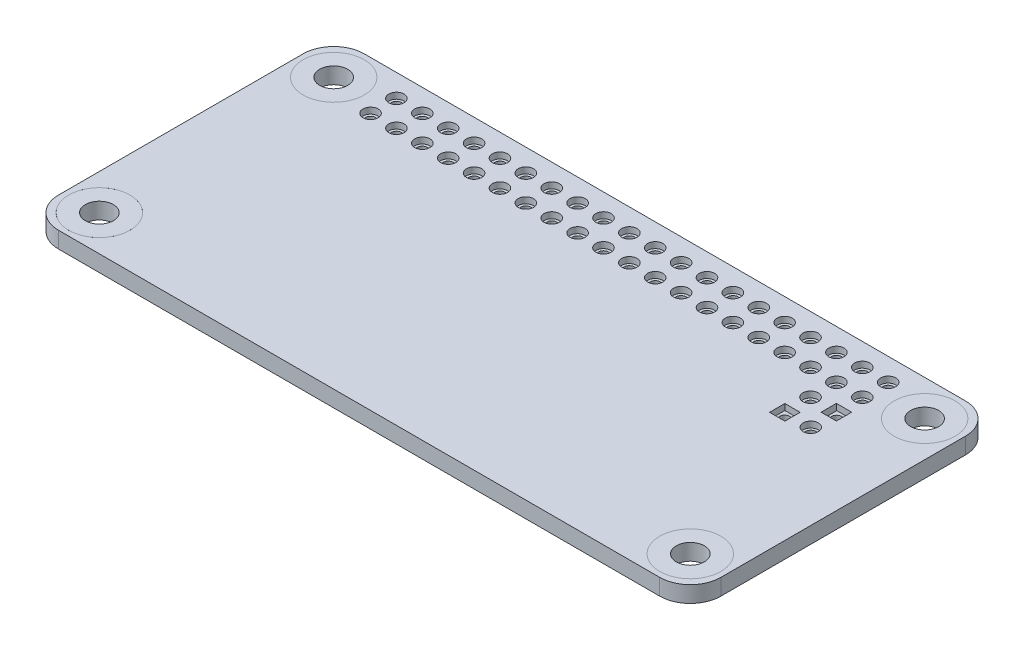
from build123d import *

# Parameters (mm, degrees)
SKETCH1_R             = 3
SKETCH1_R_2           = 0.75
SKETCH1_W             = 1.5
SKETCH1_H             = 1.5
BOSS_EXTRUDE1_DEPTH   = 1.6
SKETCH2_R             = 0.75
SKETCH2_R_2           = 0.5
BOSS_EXTRUDE2_DEPTH   = 1
LPATTERN2_COUNT       = 20
LPATTERN2_PITCH       = 2.54
LPATTERN2_2_COUNT     = 2
LPATTERN2_2_PITCH     = 2.54
SKETCH3_R             = 0.75
SKETCH3_R_2           = 0.5
BOSS_EXTRUDE3_DEPTH   = 1
BOSS_EXTRUDE3_2_DEPTH = 1
SKETCH3_W             = 1.541222488
SKETCH3_H             = 1.5
BOSS_EXTRUDE3_3_DEPTH = 1
SKETCH3_W_2           = 1.458777511
BOSS_EXTRUDE3_4_DEPTH = 1
SKETCH4_R             = 3
SKETCH4_R_2           = 1.375
BOSS_EXTRUDE4_DEPTH   = 1.6
CUT_EXTRUDE1_DEPTH    = 1


with BuildPart() as part:
    # Sketch1 → Boss-Extrude1 (new body)
    with BuildSketch(Plane(origin=(0, 0, 0), x_dir=(1, 0, 0), z_dir=(0, 1, 0))):
        with BuildLine():
            Line((-29.5, -15), (29.5, -15))
            ThreePointArc((29.5, -15), (31.621320344, -14.121320344), (32.5, -12))
            Line((32.5, -12), (32.5, 12))
            ThreePointArc((32.5, 12), (31.621320344, 14.121320344), (29.5, 15))
            Line((29.5, 15), (-29.5, 15))
            ThreePointArc((-29.5, 15), (-31.621320344, 14.121320344), (-32.5, 12))
            Line((-32.5, 12), (-32.5, -12))
            ThreePointArc((-32.5, -12), (-31.621320344, -14.121320344), (-29.5, -15))
        make_face()
        with Locations((-29, 11.5)):
            Circle(SKETCH1_R, mode=Mode.SUBTRACT)
        with Locations((-29, -11.5)):
            Circle(SKETCH1_R, mode=Mode.SUBTRACT)
        with Locations((29, -11.5)):
            Circle(SKETCH1_R, mode=Mode.SUBTRACT)
        with Locations((-24.13, 12.787653136)):
            Circle(SKETCH1_R_2, mode=Mode.SUBTRACT)
        with Locations((-21.59, 12.787653136)):
            Circle(SKETCH1_R_2, mode=Mode.SUBTRACT)
        with Locations((-19.05, 12.787653136)):
            Circle(SKETCH1_R_2, mode=Mode.SUBTRACT)
        with Locations((-16.51, 12.787653136)):
            Circle(SKETCH1_R_2, mode=Mode.SUBTRACT)
        with Locations((-13.97, 12.787653136)):
            Circle(SKETCH1_R_2, mode=Mode.SUBTRACT)
        with Locations((-11.43, 12.787653136)):
            Circle(SKETCH1_R_2, mode=Mode.SUBTRACT)
        with Locations((-8.89, 12.787653136)):
            Circle(SKETCH1_R_2, mode=Mode.SUBTRACT)
        with Locations((-6.35, 12.787653136)):
            Circle(SKETCH1_R_2, mode=Mode.SUBTRACT)
        with Locations((-3.81, 12.787653136)):
            Circle(SKETCH1_R_2, mode=Mode.SUBTRACT)
        with Locations((-1.27, 12.787653136)):
            Circle(SKETCH1_R_2, mode=Mode.SUBTRACT)
        with Locations((1.27, 12.787653136)):
            Circle(SKETCH1_R_2, mode=Mode.SUBTRACT)
        with Locations((3.81, 12.787653136)):
            Circle(SKETCH1_R_2, mode=Mode.SUBTRACT)
        with Locations((6.35, 12.787653136)):
            Circle(SKETCH1_R_2, mode=Mode.SUBTRACT)
        with Locations((8.89, 12.787653136)):
            Circle(SKETCH1_R_2, mode=Mode.SUBTRACT)
        with Locations((11.43, 12.787653136)):
            Circle(SKETCH1_R_2, mode=Mode.SUBTRACT)
        with Locations((13.97, 12.787653136)):
            Circle(SKETCH1_R_2, mode=Mode.SUBTRACT)
        with Locations((16.51, 12.787653136)):
            Circle(SKETCH1_R_2, mode=Mode.SUBTRACT)
        with Locations((19.05, 12.787653136)):
            Circle(SKETCH1_R_2, mode=Mode.SUBTRACT)
        with Locations((21.59, 12.787653136)):
            Circle(SKETCH1_R_2, mode=Mode.SUBTRACT)
        with Locations((24.13, 12.787653136)):
            Circle(SKETCH1_R_2, mode=Mode.SUBTRACT)
        with Locations((-21.59, 10.247653136)):
            Circle(SKETCH1_R_2, mode=Mode.SUBTRACT)
        with Locations((-19.05, 10.247653136)):
            Circle(SKETCH1_R_2, mode=Mode.SUBTRACT)
        with Locations((-16.51, 10.247653136)):
            Circle(SKETCH1_R_2, mode=Mode.SUBTRACT)
        with Locations((-13.97, 10.247653136)):
            Circle(SKETCH1_R_2, mode=Mode.SUBTRACT)
        with Locations((-11.43, 10.247653136)):
            Circle(SKETCH1_R_2, mode=Mode.SUBTRACT)
        with Locations((-8.89, 10.247653136)):
            Circle(SKETCH1_R_2, mode=Mode.SUBTRACT)
        with Locations((-6.35, 10.247653136)):
            Circle(SKETCH1_R_2, mode=Mode.SUBTRACT)
        with Locations((-3.81, 10.247653136)):
            Circle(SKETCH1_R_2, mode=Mode.SUBTRACT)
        with Locations((-1.27, 10.247653136)):
            Circle(SKETCH1_R_2, mode=Mode.SUBTRACT)
        with Locations((1.27, 10.247653136)):
            Circle(SKETCH1_R_2, mode=Mode.SUBTRACT)
        with Locations((3.81, 10.247653136)):
            Circle(SKETCH1_R_2, mode=Mode.SUBTRACT)
        with Locations((6.35, 10.247653136)):
            Circle(SKETCH1_R_2, mode=Mode.SUBTRACT)
        with Locations((8.89, 10.247653136)):
            Circle(SKETCH1_R_2, mode=Mode.SUBTRACT)
        with Locations((11.43, 10.247653136)):
            Circle(SKETCH1_R_2, mode=Mode.SUBTRACT)
        with Locations((13.97, 10.247653136)):
            Circle(SKETCH1_R_2, mode=Mode.SUBTRACT)
        with Locations((16.51, 10.247653136)):
            Circle(SKETCH1_R_2, mode=Mode.SUBTRACT)
        with Locations((19.05, 10.247653136)):
            Circle(SKETCH1_R_2, mode=Mode.SUBTRACT)
        with Locations((21.59, 10.247653136)):
            Circle(SKETCH1_R_2, mode=Mode.SUBTRACT)
        with Locations((24.13, 10.247653136)):
            Circle(SKETCH1_R_2, mode=Mode.SUBTRACT)
        with Locations((-24.13, 10.247653136)):
            Circle(SKETCH1_R_2, mode=Mode.SUBTRACT)
        with Locations((21.59002512, 7.707653136)):
            Circle(SKETCH1_R_2, mode=Mode.SUBTRACT)
        with Locations((24.150636364, 5.167736764)):
            Circle(SKETCH1_R_2, mode=Mode.SUBTRACT)
        with Locations((29, 11.5)):
            Circle(SKETCH1_R, mode=Mode.SUBTRACT)
        with Locations((24.13002512, 7.707653136)):
            Rectangle(SKETCH1_W, SKETCH1_H, mode=Mode.SUBTRACT)
        with Locations((21.610636364, 5.167736764)):
            Rectangle(SKETCH1_W, SKETCH1_H, mode=Mode.SUBTRACT)
    extrude(amount=BOSS_EXTRUDE1_DEPTH)

    # Sketch5 → Cut-Extrude1 (cut)
    with BuildSketch(Plane.XZ):
        with BuildLine():
            Line((-26.078842351, 13.039495396), (-26.078842351, 13.539495396))
            ThreePointArc((-26.078842351, 13.539495396), (-25.578842351, 14.039495396), (-25.078842351, 13.539495396))
            Line((-25.078842351, 13.539495396), (-25.078842351, 13.039495396))
            ThreePointArc((-25.078842351, 13.039495396), (-25.578842351, 12.539495396), (-26.078842351, 13.039495396))
        make_face()
        with BuildLine():
            Line((-15.178842351, 13.039495396), (-15.178842351, 13.539495396))
            ThreePointArc((-15.178842351, 13.539495396), (-14.678842351, 14.039495396), (-14.178842351, 13.539495396))
            Line((-14.178842351, 13.539495396), (-14.178842351, 13.039495396))
            ThreePointArc((-14.178842351, 13.039495396), (-14.678842351, 12.539495396), (-15.178842351, 13.039495396))
        make_face()
        with BuildLine():
            Line((-15.178842351, 8.539495396), (-15.178842351, 9.039495396))
            ThreePointArc((-15.178842351, 9.039495396), (-14.678842351, 9.539495396), (-14.178842351, 9.039495396))
            Line((-14.178842351, 9.039495396), (-14.178842351, 8.539495396))
            ThreePointArc((-14.178842351, 8.539495396), (-14.678842351, 8.039495396), (-15.178842351, 8.539495396))
        make_face()
        with BuildLine():
            Line((-26.078842351, 8.539495396), (-26.078842351, 9.039495396))
            ThreePointArc((-26.078842351, 9.039495396), (-25.578842351, 9.539495396), (-25.078842351, 9.039495396))
            Line((-25.078842351, 9.039495396), (-25.078842351, 8.539495396))
            ThreePointArc((-25.078842351, 8.539495396), (-25.578842351, 8.039495396), (-26.078842351, 8.539495396))
        make_face()
    extrude(amount=-CUT_EXTRUDE1_DEPTH, mode=Mode.SUBTRACT)


with BuildPart() as body_2:
    # Sketch2 → Boss-Extrude2 (new body)
    with BuildSketch(Plane(origin=(0, 0, 0), x_dir=(1, 0, 0), z_dir=(0, 1, 0))):
        with Locations((-24.13, 12.787653136)):
            Circle(SKETCH2_R)
        with Locations((-24.13, 12.787653136)):
            Circle(SKETCH2_R_2, mode=Mode.SUBTRACT)
    extrude(amount=BOSS_EXTRUDE2_DEPTH)


with BuildPart() as lpattern2_1:
    # LPattern2: pattern copy
    add(body_2.part.moved(Location(Vector(1, 0, 0) * (1 * LPATTERN2_PITCH))))


with BuildPart() as lpattern2_2:
    # LPattern2: pattern copy
    add(body_2.part.moved(Location(Vector(1, 0, 0) * (2 * LPATTERN2_PITCH))))


with BuildPart() as lpattern2_3:
    # LPattern2: pattern copy
    add(body_2.part.moved(Location(Vector(1, 0, 0) * (3 * LPATTERN2_PITCH))))


with BuildPart() as lpattern2_4:
    # LPattern2: pattern copy
    add(body_2.part.moved(Location(Vector(1, 0, 0) * (4 * LPATTERN2_PITCH))))


with BuildPart() as lpattern2_5:
    # LPattern2: pattern copy
    add(body_2.part.moved(Location(Vector(1, 0, 0) * (5 * LPATTERN2_PITCH))))


with BuildPart() as lpattern2_6:
    # LPattern2: pattern copy
    add(body_2.part.moved(Location(Vector(1, 0, 0) * (6 * LPATTERN2_PITCH))))


with BuildPart() as lpattern2_7:
    # LPattern2: pattern copy
    add(body_2.part.moved(Location(Vector(1, 0, 0) * (7 * LPATTERN2_PITCH))))


with BuildPart() as lpattern2_8:
    # LPattern2: pattern copy
    add(body_2.part.moved(Location(Vector(1, 0, 0) * (8 * LPATTERN2_PITCH))))


with BuildPart() as lpattern2_9:
    # LPattern2: pattern copy
    add(body_2.part.moved(Location(Vector(1, 0, 0) * (9 * LPATTERN2_PITCH))))


with BuildPart() as lpattern2_10:
    # LPattern2: pattern copy
    add(body_2.part.moved(Location(Vector(1, 0, 0) * (10 * LPATTERN2_PITCH))))


with BuildPart() as lpattern2_11:
    # LPattern2: pattern copy
    add(body_2.part.moved(Location(Vector(1, 0, 0) * (11 * LPATTERN2_PITCH))))


with BuildPart() as lpattern2_12:
    # LPattern2: pattern copy
    add(body_2.part.moved(Location(Vector(1, 0, 0) * (12 * LPATTERN2_PITCH))))


with BuildPart() as lpattern2_13:
    # LPattern2: pattern copy
    add(body_2.part.moved(Location(Vector(1, 0, 0) * (13 * LPATTERN2_PITCH))))


with BuildPart() as lpattern2_14:
    # LPattern2: pattern copy
    add(body_2.part.moved(Location(Vector(1, 0, 0) * (14 * LPATTERN2_PITCH))))


with BuildPart() as lpattern2_15:
    # LPattern2: pattern copy
    add(body_2.part.moved(Location(Vector(1, 0, 0) * (15 * LPATTERN2_PITCH))))


with BuildPart() as lpattern2_16:
    # LPattern2: pattern copy
    add(body_2.part.moved(Location(Vector(1, 0, 0) * (16 * LPATTERN2_PITCH))))


with BuildPart() as lpattern2_17:
    # LPattern2: pattern copy
    add(body_2.part.moved(Location(Vector(1, 0, 0) * (17 * LPATTERN2_PITCH))))


with BuildPart() as lpattern2_18:
    # LPattern2: pattern copy
    add(body_2.part.moved(Location(Vector(1, 0, 0) * (18 * LPATTERN2_PITCH))))


with BuildPart() as lpattern2_19:
    # LPattern2: pattern copy
    add(body_2.part.moved(Location(Vector(1, 0, 0) * (19 * LPATTERN2_PITCH))))


with BuildPart() as lpattern2_2_1:
    # LPattern2 2: pattern copy
    add(body_2.part.moved(Location(Vector(0, 0, 1) * (1 * LPATTERN2_2_PITCH))))


with BuildPart() as lpattern2_2_2:
    # LPattern2 2: pattern copy
    add(lpattern2_1.part.moved(Location(Vector(0, 0, 1) * (1 * LPATTERN2_2_PITCH))))


with BuildPart() as lpattern2_2_3:
    # LPattern2 2: pattern copy
    add(lpattern2_2.part.moved(Location(Vector(0, 0, 1) * (1 * LPATTERN2_2_PITCH))))


with BuildPart() as lpattern2_2_4:
    # LPattern2 2: pattern copy
    add(lpattern2_3.part.moved(Location(Vector(0, 0, 1) * (1 * LPATTERN2_2_PITCH))))


with BuildPart() as lpattern2_2_5:
    # LPattern2 2: pattern copy
    add(lpattern2_4.part.moved(Location(Vector(0, 0, 1) * (1 * LPATTERN2_2_PITCH))))


with BuildPart() as lpattern2_2_6:
    # LPattern2 2: pattern copy
    add(lpattern2_5.part.moved(Location(Vector(0, 0, 1) * (1 * LPATTERN2_2_PITCH))))


with BuildPart() as lpattern2_2_7:
    # LPattern2 2: pattern copy
    add(lpattern2_6.part.moved(Location(Vector(0, 0, 1) * (1 * LPATTERN2_2_PITCH))))


with BuildPart() as lpattern2_2_8:
    # LPattern2 2: pattern copy
    add(lpattern2_7.part.moved(Location(Vector(0, 0, 1) * (1 * LPATTERN2_2_PITCH))))


with BuildPart() as lpattern2_2_9:
    # LPattern2 2: pattern copy
    add(lpattern2_8.part.moved(Location(Vector(0, 0, 1) * (1 * LPATTERN2_2_PITCH))))


with BuildPart() as lpattern2_2_10:
    # LPattern2 2: pattern copy
    add(lpattern2_9.part.moved(Location(Vector(0, 0, 1) * (1 * LPATTERN2_2_PITCH))))


with BuildPart() as lpattern2_2_11:
    # LPattern2 2: pattern copy
    add(lpattern2_10.part.moved(Location(Vector(0, 0, 1) * (1 * LPATTERN2_2_PITCH))))


with BuildPart() as lpattern2_2_12:
    # LPattern2 2: pattern copy
    add(lpattern2_11.part.moved(Location(Vector(0, 0, 1) * (1 * LPATTERN2_2_PITCH))))


with BuildPart() as lpattern2_2_13:
    # LPattern2 2: pattern copy
    add(lpattern2_12.part.moved(Location(Vector(0, 0, 1) * (1 * LPATTERN2_2_PITCH))))


with BuildPart() as lpattern2_2_14:
    # LPattern2 2: pattern copy
    add(lpattern2_13.part.moved(Location(Vector(0, 0, 1) * (1 * LPATTERN2_2_PITCH))))


with BuildPart() as lpattern2_2_15:
    # LPattern2 2: pattern copy
    add(lpattern2_14.part.moved(Location(Vector(0, 0, 1) * (1 * LPATTERN2_2_PITCH))))


with BuildPart() as lpattern2_2_16:
    # LPattern2 2: pattern copy
    add(lpattern2_15.part.moved(Location(Vector(0, 0, 1) * (1 * LPATTERN2_2_PITCH))))


with BuildPart() as lpattern2_2_17:
    # LPattern2 2: pattern copy
    add(lpattern2_16.part.moved(Location(Vector(0, 0, 1) * (1 * LPATTERN2_2_PITCH))))


with BuildPart() as lpattern2_2_18:
    # LPattern2 2: pattern copy
    add(lpattern2_17.part.moved(Location(Vector(0, 0, 1) * (1 * LPATTERN2_2_PITCH))))


with BuildPart() as lpattern2_2_19:
    # LPattern2 2: pattern copy
    add(lpattern2_18.part.moved(Location(Vector(0, 0, 1) * (1 * LPATTERN2_2_PITCH))))


with BuildPart() as lpattern2_2_20:
    # LPattern2 2: pattern copy
    add(lpattern2_19.part.moved(Location(Vector(0, 0, 1) * (1 * LPATTERN2_2_PITCH))))


with BuildPart() as body_42:
    # Sketch3 → Boss-Extrude3 (new body)
    with BuildSketch(Plane(origin=(0, 0, 0), x_dir=(1, 0, 0), z_dir=(0, 1, 0))):
        with Locations((21.59002512, 7.707653136)):
            Circle(SKETCH3_R)
        with Locations((21.59002512, 7.707653136)):
            Circle(SKETCH3_R_2, mode=Mode.SUBTRACT)
    extrude(amount=BOSS_EXTRUDE3_DEPTH)


with BuildPart() as body_43:
    # Sketch3 → Boss-Extrude3 2 (new body)
    with BuildSketch(Plane(origin=(0, 0, 0), x_dir=(1, 0, 0), z_dir=(0, 1, 0))):
        with Locations((24.150636364, 5.167736764)):
            Circle(SKETCH3_R)
        with Locations((24.150636364, 5.167736764)):
            Circle(SKETCH3_R_2, mode=Mode.SUBTRACT)
    extrude(amount=BOSS_EXTRUDE3_2_DEPTH)


with BuildPart() as body_44:
    # Sketch3 → Boss-Extrude3 3 (new body)
    with BuildSketch(Plane(origin=(0, 0, 0), x_dir=(1, 0, 0), z_dir=(0, 1, 0))):
        with Locations((21.59002512, 5.167736764)):
            Rectangle(SKETCH3_W, SKETCH3_H)
        with Locations((21.59002512, 5.167736764)):
            Circle(SKETCH3_R_2, mode=Mode.SUBTRACT)
    extrude(amount=BOSS_EXTRUDE3_3_DEPTH)


with BuildPart() as body_45:
    # Sketch3 → Boss-Extrude3 4 (new body)
    with BuildSketch(Plane(origin=(0, 0, 0), x_dir=(1, 0, 0), z_dir=(0, 1, 0))):
        with Locations((24.150636365, 7.707653136)):
            Rectangle(SKETCH3_W_2, SKETCH3_H)
        with Locations((24.150636364, 7.707653136)):
            Circle(SKETCH3_R_2, mode=Mode.SUBTRACT)
    extrude(amount=BOSS_EXTRUDE3_4_DEPTH)


with BuildPart() as body_46:
    # Sketch4 → Boss-Extrude4 (new body)
    with BuildSketch(Plane(origin=(0, 0, 0), x_dir=(1, 0, 0), z_dir=(0, 1, 0))):
        with Locations((-29, 11.5)):
            Circle(SKETCH4_R)
        with Locations((-29, 11.5)):
            Circle(SKETCH4_R_2, mode=Mode.SUBTRACT)
    extrude(amount=BOSS_EXTRUDE4_DEPTH)


with BuildPart() as body_47:
    # Mirror1: mirrored copy
    add(body_46.part.mirror(Plane(origin=(0, 0, 0), x_dir=(0, 0, 1), z_dir=(1, 0, 0))))


with BuildPart() as body_48:
    # Mirror2: mirrored copy
    add(body_46.part.mirror(Plane.XY))


with BuildPart() as body_49:
    # Mirror2 2: mirrored copy
    add(body_47.part.mirror(Plane.XY))


solid = Compound([part.part, body_2.part, lpattern2_1.part, lpattern2_2.part, lpattern2_3.part, lpattern2_4.part, lpattern2_5.part, lpattern2_6.part, lpattern2_7.part, lpattern2_8.part, lpattern2_9.part, lpattern2_10.part, lpattern2_11.part, lpattern2_12.part, lpattern2_13.part, lpattern2_14.part, lpattern2_15.part, lpattern2_16.part, lpattern2_17.part, lpattern2_18.part, lpattern2_19.part, lpattern2_2_1.part, lpattern2_2_2.part, lpattern2_2_3.part, lpattern2_2_4.part, lpattern2_2_5.part, lpattern2_2_6.part, lpattern2_2_7.part, lpattern2_2_8.part, lpattern2_2_9.part, lpattern2_2_10.part, lpattern2_2_11.part, lpattern2_2_12.part, lpattern2_2_13.part, lpattern2_2_14.part, lpattern2_2_15.part, lpattern2_2_16.part, lpattern2_2_17.part, lpattern2_2_18.part, lpattern2_2_19.part, lpattern2_2_20.part, body_42.part, body_43.part, body_44.part, body_45.part, body_46.part, body_47.part, body_48.part, body_49.part])
